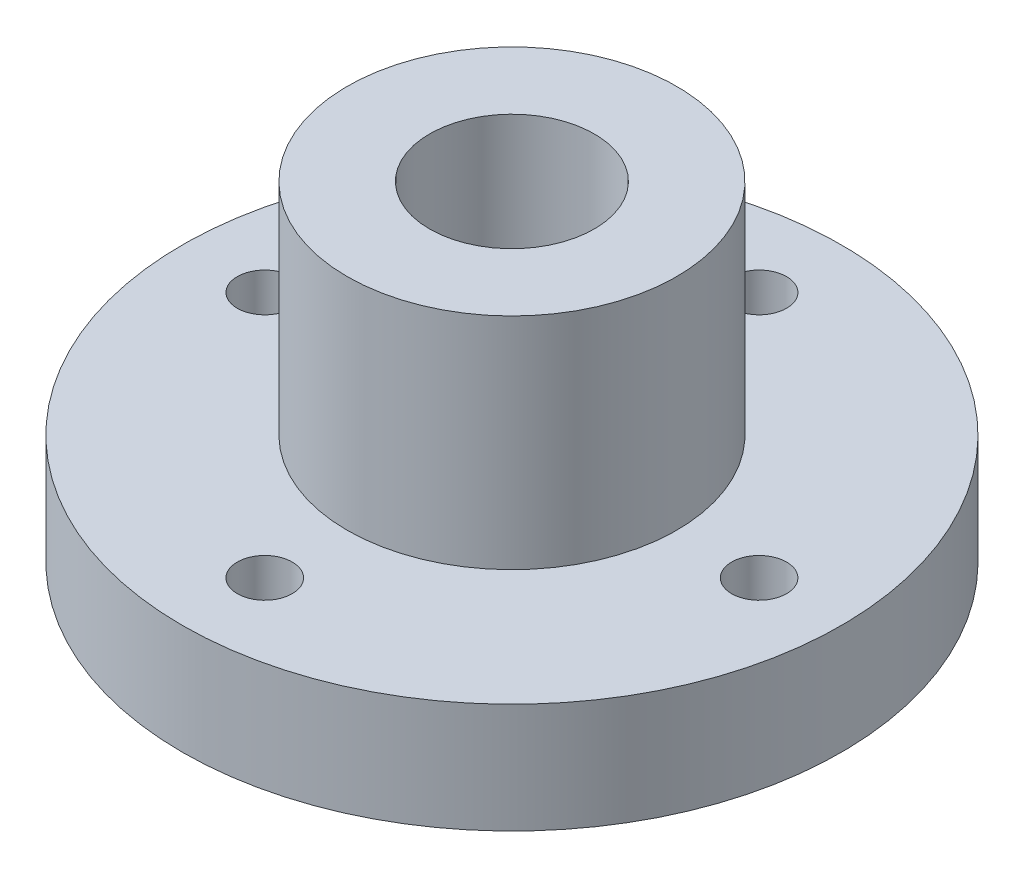
from build123d import *

# Parameters (mm, degrees)
SKETCH1_R           = 3
SKETCH1_R_2         = 0.25
SKETCH1_R_3         = 1.5
BOSS_EXTRUDE1_DEPTH = 1
SKETCH1_3_R         = 1.5
SKETCH1_3_R_2       = 0.75
BOSS_EXTRUDE2_DEPTH = 3


with BuildPart() as part:
    # Sketch1 → Boss-Extrude1 (new body)
    with BuildSketch(Plane(origin=(0, 0, 0), x_dir=(1, 0, 0), z_dir=(0, 1, 0))):
        Circle(SKETCH1_R)
        with Locations((0, -2.25)):
            Circle(SKETCH1_R_2, mode=Mode.SUBTRACT)
        with Locations((2.25, 0)):
            Circle(SKETCH1_R_2, mode=Mode.SUBTRACT)
        with Locations((-2.25, 0)):
            Circle(SKETCH1_R_2, mode=Mode.SUBTRACT)
        Circle(SKETCH1_R_3, mode=Mode.SUBTRACT)
        with Locations((0, 2.25)):
            Circle(SKETCH1_R_2, mode=Mode.SUBTRACT)
    extrude(amount=BOSS_EXTRUDE1_DEPTH)

    # Sketch1_3 → Boss-Extrude2 (add)
    with BuildSketch(Plane(origin=(0, 0, 0), x_dir=(1, 0, 0), z_dir=(0, 1, 0))):
        Circle(SKETCH1_3_R)
        Circle(SKETCH1_3_R_2, mode=Mode.SUBTRACT)
    extrude(amount=BOSS_EXTRUDE2_DEPTH)


solid = part.part
